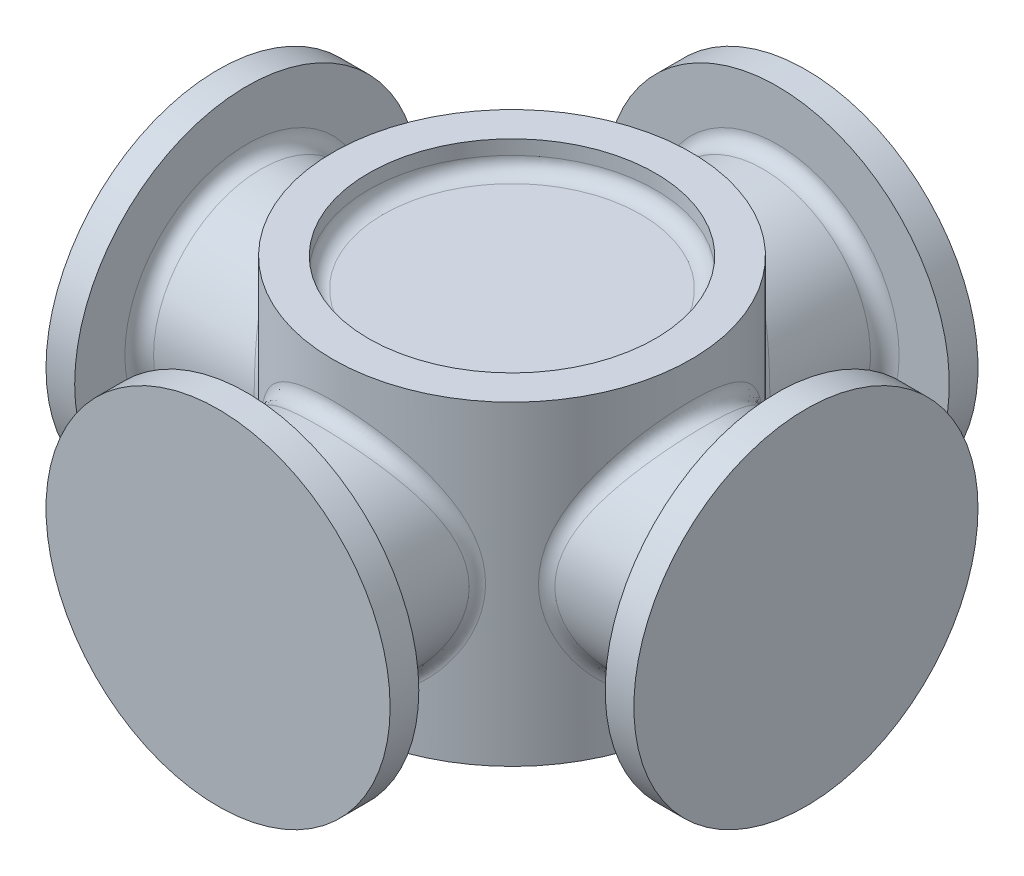
from build123d import *

# Parameters (mm, degrees)
SKETCH3_R           = 15.875
BOSS_EXTRUDE2_DEPTH = 27.94
BOSS_EXTRUDE3_START = -3.175
SKETCH4_R           = 9.525
BOSS_EXTRUDE3_DEPTH = 13.335
SKETCH5_R           = 15.24
BOSS_EXTRUDE4_DEPTH = 2.54
CIRPATTERN1_COUNT   = 4
FILLET1_R           = 1.27
FILLET2_R           = 1.27
SKETCH6_R           = 12.7
CUT_EXTRUDE1_DEPTH  = 2.54
FILLET3_R           = 1.27
SKETCH7_R           = 12.7
CUT_EXTRUDE2_DEPTH  = 2.54
FILLET4_R           = 1.27


with BuildPart() as part:
    # Sketch3 → Boss-Extrude2 (new body)
    with BuildSketch(Plane(origin=(0, 0, 0), x_dir=(1, 0, 0), z_dir=(0, 1, 0))):
        Circle(SKETCH3_R)
    extrude(amount=BOSS_EXTRUDE2_DEPTH)

    # Sketch4 → Boss-Extrude3 (add)
    with BuildSketch(Plane.XY.offset(15.875).offset(BOSS_EXTRUDE3_START)):
        with Locations((0, 13.97)):
            Circle(SKETCH4_R)
    boss_extrude3 = extrude(amount=BOSS_EXTRUDE3_DEPTH)

    # Sketch5 → Boss-Extrude4 (add)
    with BuildSketch(Plane.XY.offset(26.035)):
        with Locations((0, 13.97)):
            Circle(SKETCH5_R)
    boss_extrude4 = extrude(amount=-BOSS_EXTRUDE4_DEPTH)

    # CirPattern1: Boss-Extrude3, Boss-Extrude4 ×4 about axis
    cirpattern1_axis = Axis((0, 0, 0), (0, 1, 0))
    for i in range(1, CIRPATTERN1_COUNT):
        add(boss_extrude3.rotate(cirpattern1_axis, i * 360 / CIRPATTERN1_COUNT))
        add(boss_extrude4.rotate(cirpattern1_axis, i * 360 / CIRPATTERN1_COUNT))

    # Fillet1
    fillet1_edges = [part.edges().sort_by_distance(p)[0] for p in [
        (14.369481872, 7.247499776, -6.747860086),
        (9.525, 13.97, -12.7),
        (-12.7, 13.97, -9.525),
        (-9.525, 13.97, 12.7),
    ]]
    fillet(fillet1_edges, radius=FILLET1_R)

    # Fillet2
    fillet2_edges = [part.edges().sort_by_distance(p)[0] for p in [
        (23.495, 13.97, 9.525),
        (9.525, 13.97, -23.495),
        (-23.495, 13.97, -9.525),
        (-9.525, 13.97, 23.495),
    ]]
    fillet(fillet2_edges, radius=FILLET2_R)

    # Sketch6 → Cut-Extrude1 (cut)
    with BuildSketch(Plane(origin=(0, 27.94, 0), x_dir=(1, 0, 0), z_dir=(0, 1, 0))):
        Circle(SKETCH6_R)
    extrude(amount=-CUT_EXTRUDE1_DEPTH, mode=Mode.SUBTRACT)

    # Fillet3
    fillet3_edges = [part.edges().sort_by_distance(p)[0] for p in [
        (-12.7, 25.4, 0),
    ]]
    fillet(fillet3_edges, radius=FILLET3_R)

    # Sketch7 → Cut-Extrude2 (cut)
    with BuildSketch(Plane.XZ):
        Circle(SKETCH7_R)
    extrude(amount=-CUT_EXTRUDE2_DEPTH, mode=Mode.SUBTRACT)

    # Fillet4
    fillet4_edges = [part.edges().sort_by_distance(p)[0] for p in [
        (-12.7, 2.54, 0),
    ]]
    fillet(fillet4_edges, radius=FILLET4_R)


solid = part.part
